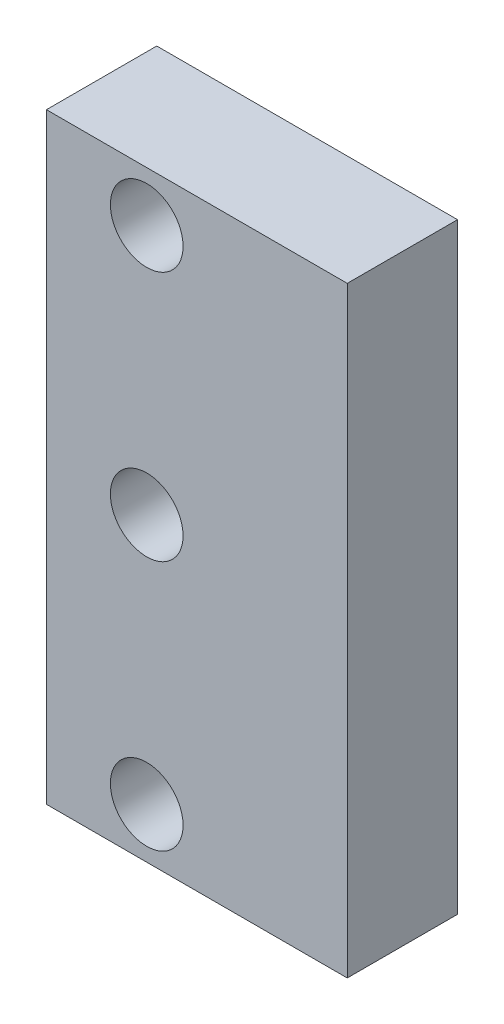
from build123d import *

# Parameters (mm, degrees)
SKETCH_1_W      = 30
SKETCH_1_H      = 60
SKETCH_1_R      = 3.625
EXTRUDE_1_DEPTH = 11


with BuildPart() as part:
    # 스케치1 → 보스-돌출1 (new body)
    with BuildSketch(Plane.XY):
        Rectangle(SKETCH_1_W, SKETCH_1_H)
        with Locations((-5, 25)):
            Circle(SKETCH_1_R, mode=Mode.SUBTRACT)
        with Locations((-5, 0)):
            Circle(SKETCH_1_R, mode=Mode.SUBTRACT)
        with Locations((-5, -25)):
            Circle(SKETCH_1_R, mode=Mode.SUBTRACT)
    extrude(amount=EXTRUDE_1_DEPTH)


solid = part.part
